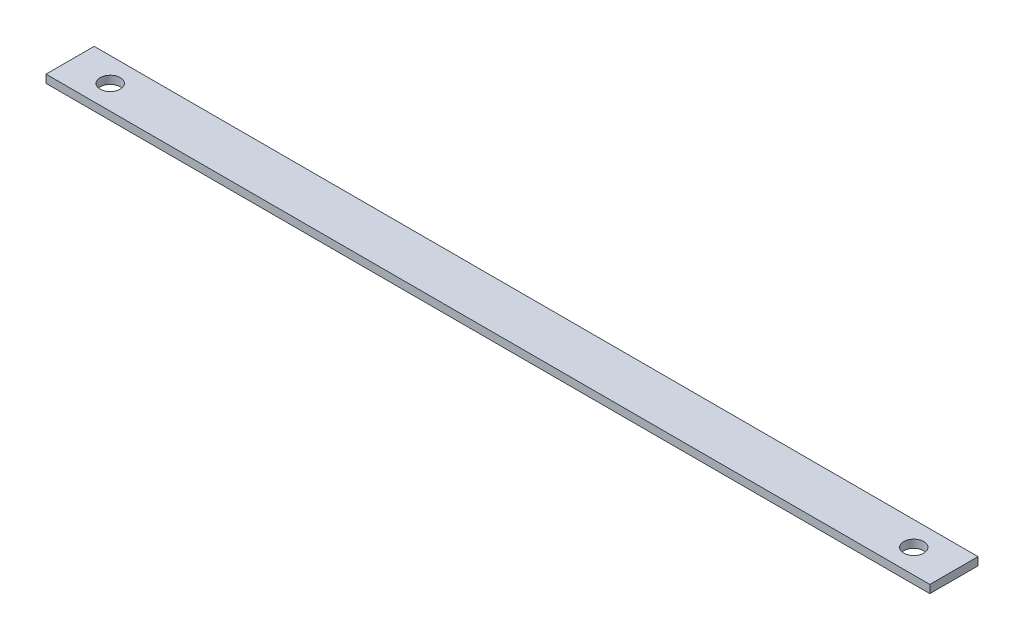
from build123d import *

# Parameters (mm, degrees)
SKETCH1_W                 = 220.18723
SKETCH1_H                 = 12
BOSS_EXTRUDE1_DEPTH       = 2
F_5_0MM_DOWEL_HOLE1_D     = 5
F_5_0MM_DOWEL_HOLE1_DEPTH = 2


with BuildPart() as part:
    # Sketch1 → Boss-Extrude1 (new body)
    with BuildSketch(Plane(origin=(0, 0, 0), x_dir=(1, 0, 0), z_dir=(0, 1, 0))):
        Rectangle(SKETCH1_W, SKETCH1_H)
    extrude(amount=BOSS_EXTRUDE1_DEPTH)

    # Ø5.0mm Dowel Hole1
    with Locations(Plane(origin=(0, 2, 0), x_dir=(1, 0, 0), z_dir=(0, 1, 0))):
        with Locations((-100.093615, 0), (100.093615, 0)):
            Hole(F_5_0MM_DOWEL_HOLE1_D / 2, depth=F_5_0MM_DOWEL_HOLE1_DEPTH)


solid = part.part
